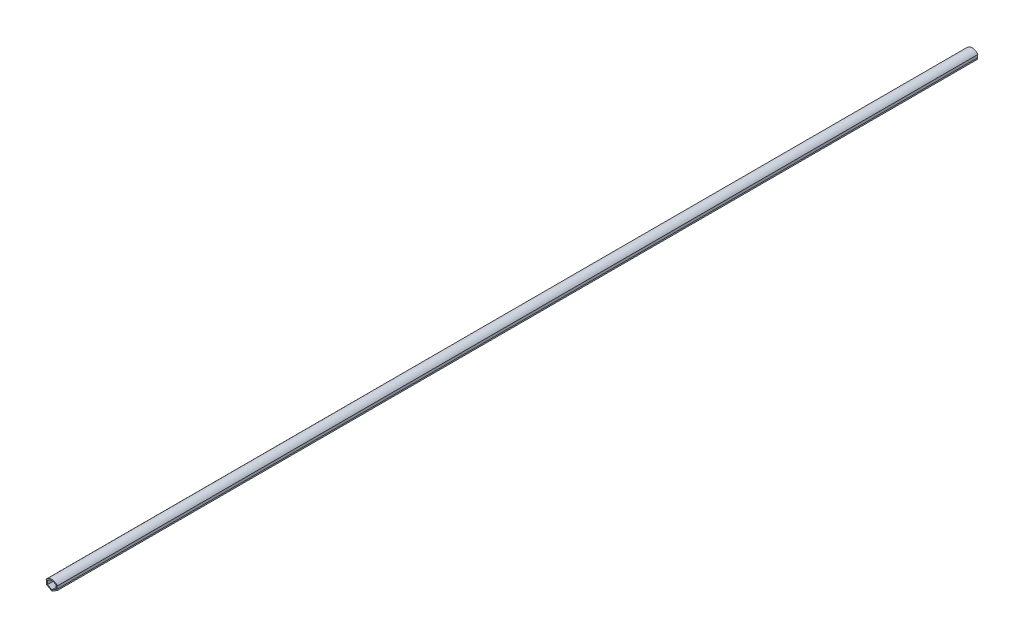
from build123d import *

# Parameters (mm, degrees)
EXTRUDE_1_DEPTH = 1000


with BuildPart() as part:
    # Эскиз1 → Бобышка-Вытянуть1 (new body)
    with BuildSketch(Plane.XY):
        with BuildLine():
            Line((0, 0), (-6.1, 3.521836642))
            Line((-6.1, 3.521836642), (-5.6, 4.387862046))
            Line((-5.6, 4.387862046), (-5.6, 8.00799361))
            Line((-5.6, 8.00799361), (-6.238589584, 8.00799361))
            ThreePointArc((-6.238589584, 8.00799361), (0, 11), (6.238589584, 8.00799361))
            Line((6.238589584, 8.00799361), (5.6, 8.00799361))
            Line((5.6, 8.00799361), (5.6, 4.387862046))
            Line((5.6, 4.387862046), (6.1, 3.521836642))
            Line((6.1, 3.521836642), (0, 0))
        make_face()
        with BuildLine():
            Line((0, 1.154700538), (-4.6, 3.810511777))
            Line((-4.6, 3.810511777), (-4.6, 8.00799361))
            ThreePointArc((-4.6, 8.00799361), (0, 9.8), (4.6, 8.00799361))
            Line((4.6, 8.00799361), (4.6, 3.810511777))
            Line((4.6, 3.810511777), (0, 1.154700538))
        make_face(mode=Mode.SUBTRACT)
    extrude(amount=EXTRUDE_1_DEPTH)


solid = part.part
